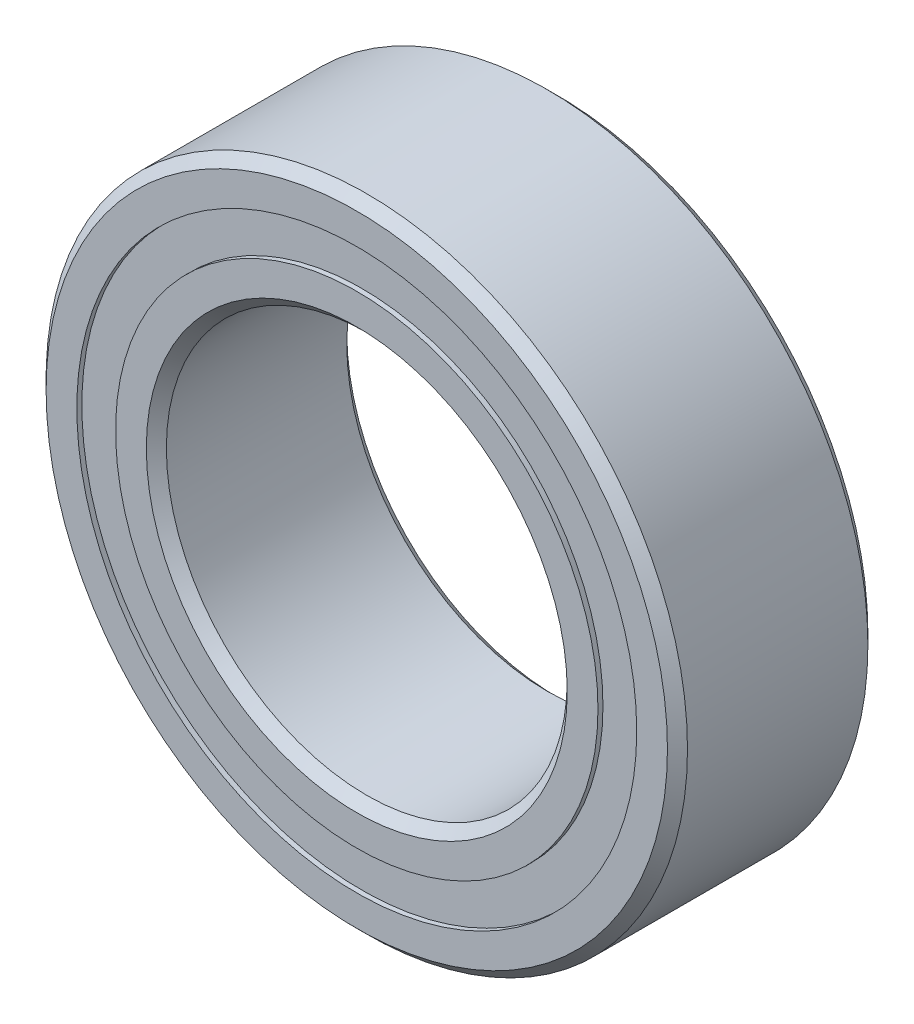
from build123d import *

# Parameters (mm, degrees)
CIRPATTERN1_COUNT = 12
SKETCH5_W         = 0.58162128
SKETCH5_H         = 0.483516484


with BuildPart() as part:
    # Sketch1 → Revolve1 (revolve)
    with BuildSketch(Plane(origin=(0, 0, 0), x_dir=(0, 0, -1), z_dir=(1, 0, 0))):
        with BuildLine():
            Line((1.125, 4), (-1.125, 4))
            Line((-1.125, 4), (-1.25, 3.875))
            Line((-1.25, 3.875), (-1.25, 3.491758242))
            Line((-1.25, 3.491758242), (-0.555555556, 3.491758242))
            ThreePointArc((-0.555555556, 3.491758242), (0, 3.85587872), (0.555555556, 3.491758242))
            Line((0.555555556, 3.491758242), (1.25, 3.491758242))
            Line((1.25, 3.491758242), (1.25, 3.875))
            Line((1.25, 3.875), (1.125, 4))
        make_face()
    revolve(axis=Axis((0, 0, 1.25), (0, 0, -1)))


with BuildPart() as body_2:
    # Sketch3 → Revolve3 (revolve)
    with BuildSketch(Plane(origin=(0, 0, 0), x_dir=(0, 0, -1), z_dir=(1, 0, 0))):
        with BuildLine():
            Line((-1.25, 3.008241758), (-0.555555556, 3.008241758))
            ThreePointArc((-0.555555556, 3.008241758), (0, 2.64412128), (0.555555556, 3.008241758))
            Line((0.555555556, 3.008241758), (1.25, 3.008241758))
            Line((1.25, 3.008241758), (1.25, 2.625))
            Line((1.25, 2.625), (1.125, 2.5))
            Line((1.125, 2.5), (-1.125, 2.5))
            Line((-1.125, 2.5), (-1.25, 2.625))
            Line((-1.25, 2.625), (-1.25, 3.008241758))
        make_face()
    revolve(axis=Axis((0, 0, 1.25), (0, 0, -1)))


with BuildPart() as body_3:
    # Sketch4 → Revolve4 (revolve)
    with BuildSketch(Plane(origin=(0, 0, 0), x_dir=(0, 0, -1), z_dir=(1, 0, 0))):
        with BuildLine():
            Line((-0.60587872, 3.25), (0.60587872, 3.25))
            ThreePointArc((0.60587872, 3.25), (0, 3.85587872), (-0.60587872, 3.25))
        make_face()
    revolve(axis=Axis((0, 3.25, 0.60587872), (0, 0, -1)))


with BuildPart() as cirpattern1_1:
    # CirPattern1: pattern copy
    add(body_3.part.rotate(Axis((0, 0, -1.25), (0, 0, 1)), 1 * 360 / CIRPATTERN1_COUNT))


with BuildPart() as cirpattern1_2:
    # CirPattern1: pattern copy
    add(body_3.part.rotate(Axis((0, 0, -1.25), (0, 0, 1)), 2 * 360 / CIRPATTERN1_COUNT))


with BuildPart() as cirpattern1_3:
    # CirPattern1: pattern copy
    add(body_3.part.rotate(Axis((0, 0, -1.25), (0, 0, 1)), 3 * 360 / CIRPATTERN1_COUNT))


with BuildPart() as cirpattern1_4:
    # CirPattern1: pattern copy
    add(body_3.part.rotate(Axis((0, 0, -1.25), (0, 0, 1)), 4 * 360 / CIRPATTERN1_COUNT))


with BuildPart() as cirpattern1_5:
    # CirPattern1: pattern copy
    add(body_3.part.rotate(Axis((0, 0, -1.25), (0, 0, 1)), 5 * 360 / CIRPATTERN1_COUNT))


with BuildPart() as cirpattern1_6:
    # CirPattern1: pattern copy
    add(body_3.part.rotate(Axis((0, 0, -1.25), (0, 0, 1)), 6 * 360 / CIRPATTERN1_COUNT))


with BuildPart() as cirpattern1_7:
    # CirPattern1: pattern copy
    add(body_3.part.rotate(Axis((0, 0, -1.25), (0, 0, 1)), 7 * 360 / CIRPATTERN1_COUNT))


with BuildPart() as cirpattern1_8:
    # CirPattern1: pattern copy
    add(body_3.part.rotate(Axis((0, 0, -1.25), (0, 0, 1)), 8 * 360 / CIRPATTERN1_COUNT))


with BuildPart() as cirpattern1_9:
    # CirPattern1: pattern copy
    add(body_3.part.rotate(Axis((0, 0, -1.25), (0, 0, 1)), 9 * 360 / CIRPATTERN1_COUNT))


with BuildPart() as cirpattern1_10:
    # CirPattern1: pattern copy
    add(body_3.part.rotate(Axis((0, 0, -1.25), (0, 0, 1)), 10 * 360 / CIRPATTERN1_COUNT))


with BuildPart() as cirpattern1_11:
    # CirPattern1: pattern copy
    add(body_3.part.rotate(Axis((0, 0, -1.25), (0, 0, 1)), 11 * 360 / CIRPATTERN1_COUNT))


with BuildPart() as body_15:
    # Sketch5 → Revolve5 (revolve)
    with BuildSketch(Plane(origin=(0, 0, 0), x_dir=(0, 0, -1), z_dir=(1, 0, 0))):
        with Locations((-0.89668936, 3.25)):
            Rectangle(SKETCH5_W, SKETCH5_H)
        with Locations((0.89668936, 3.25)):
            Rectangle(SKETCH5_W, SKETCH5_H)
    revolve(axis=Axis((0, 0, 1.25), (0, 0, -1)))


solid = Compound([part.part, body_2.part, body_3.part, cirpattern1_1.part, cirpattern1_2.part, cirpattern1_3.part, cirpattern1_4.part, cirpattern1_5.part, cirpattern1_6.part, cirpattern1_7.part, cirpattern1_8.part, cirpattern1_9.part, cirpattern1_10.part, cirpattern1_11.part, body_15.part])
